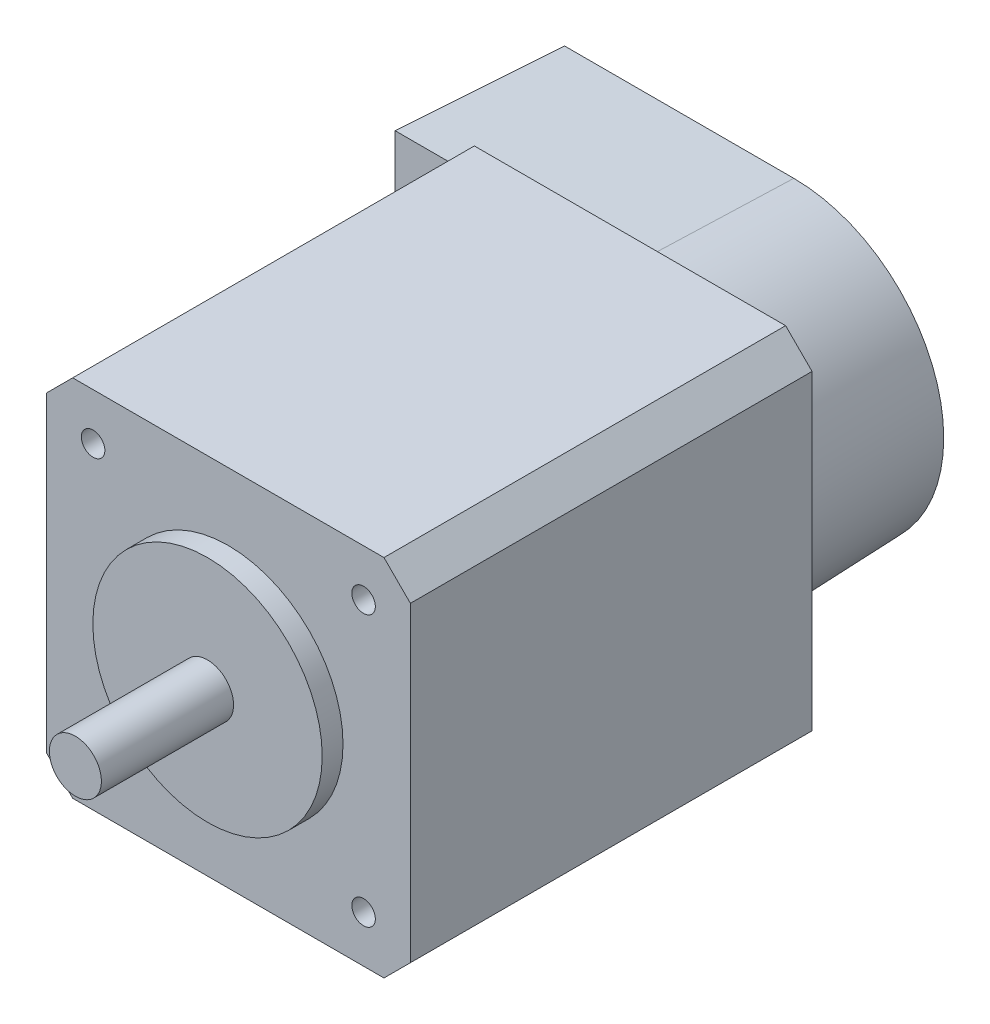
from build123d import *

# Parameters (mm, degrees)
SKETCH1_W             = 35
SKETCH1_H             = 35
BOSS_EXTRUDE1_DEPTH   = 38.608
CHAMFER1_SIZE         = 2.54
SKETCH2_R             = 11.0236
BOSS_EXTRUDE2_DEPTH   = 2
SKETCH3_R             = 2.5
BOSS_EXTRUDE3_DEPTH   = 12.7
F_4_40_TAPPED_HOLE1_D = 2.2606
BOSS_EXTRUDE4_DEPTH   = 15.748
BOSS_EXTRUDE4_TAPER   = 2


with BuildPart() as part:
    # Sketch1 → Boss-Extrude1 (new body)
    with BuildSketch(Plane.XY):
        with Locations((17.5, 17.5)):
            Rectangle(SKETCH1_W, SKETCH1_H)
    extrude(amount=BOSS_EXTRUDE1_DEPTH)

    # Chamfer1
    chamfer1_edges = [part.edges().sort_by_distance(p)[0] for p in [
        (0, 35, 19.304),
        (35, 35, 19.304),
        (35, 0, 19.304),
        (0, 0, 19.304),
    ]]
    chamfer(chamfer1_edges, length=CHAMFER1_SIZE)

    # Sketch2 → Boss-Extrude2 (add)
    with BuildSketch(Plane.XY.offset(38.608)):
        with Locations(Location((17.5, 17.5, 0), (0, 0, 180))):  # turned: the seam where the file's is
            Circle(SKETCH2_R)
    extrude(amount=BOSS_EXTRUDE2_DEPTH)

    # Sketch3 → Boss-Extrude3 (add)
    with BuildSketch(Plane.XY.offset(40.608)):
        with Locations((17.5, 17.5)):
            Circle(SKETCH3_R)
    extrude(amount=BOSS_EXTRUDE3_DEPTH)

    # #4-40 Tapped Hole1 (through all)
    with Locations(Plane.XY.offset(38.608)):
        with Locations((4.5, 30.5), (30.5, 4.5), (4.5, 4.5), (30.5, 30.5)):
            Hole(F_4_40_TAPPED_HOLE1_D / 2)

    # Sketch6 → Boss-Extrude4 (add)
    with BuildSketch(Plane(origin=(0, 0, 0), x_dir=(-1, 0, 0), z_dir=(0, 0, -1))):
        with BuildLine():
            Line((5.08, 2.54), (5.08, 32.46))
            Line((5.08, 32.46), (-17.5, 32.46))
            ThreePointArc((-17.5, 32.46), (-32.46, 17.5), (-17.5, 2.54))
            Line((-17.5, 2.54), (5.08, 2.54))
        make_face()
    extrude(amount=BOSS_EXTRUDE4_DEPTH, taper=BOSS_EXTRUDE4_TAPER)


solid = part.part
